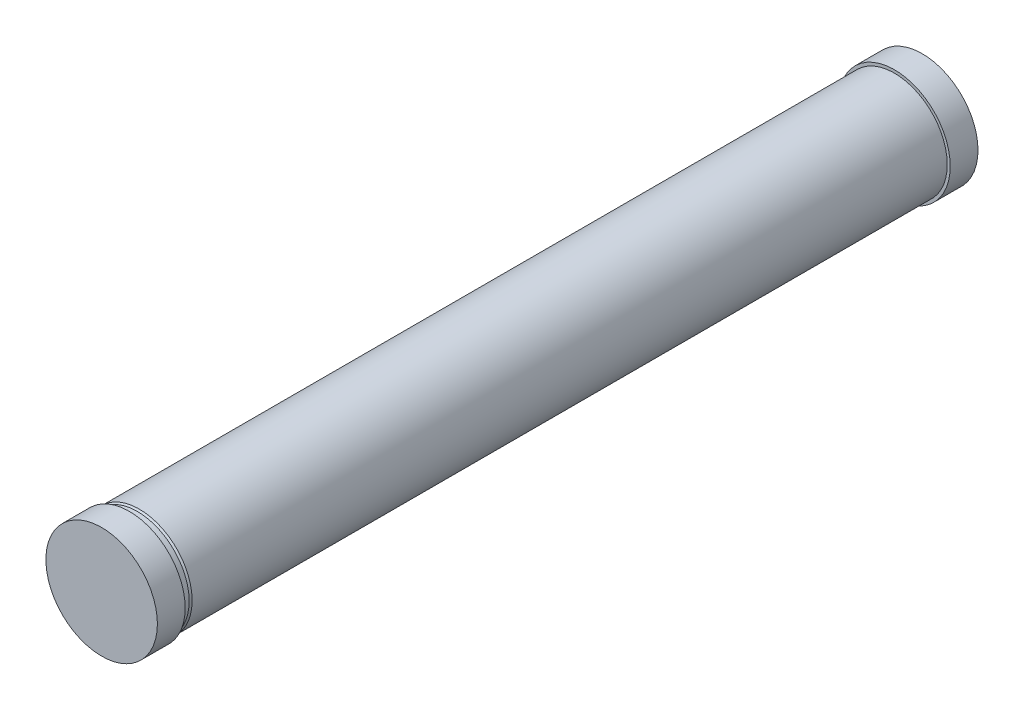
from build123d import *


with BuildPart() as part:
    # Sketch2 → Revolve1 (revolve)
    with BuildSketch(Plane(origin=(0, 0, 0), x_dir=(0, 0, -1), z_dir=(1, 0, 0))):
        Polygon((0, 130.489816683), (0, -10.010183317), (2068, -10.010183317), (2068, 130.489816683), (1998, 130.489816683), (1998, 122.989816683), (95, 122.989816683), (90, 120.489816683), (75, 120.489816683), (70, 130.489816683), align=None)
    revolve(axis=Axis((0, -10.010183317, 0), (0, 0, -1)))


solid = part.part
